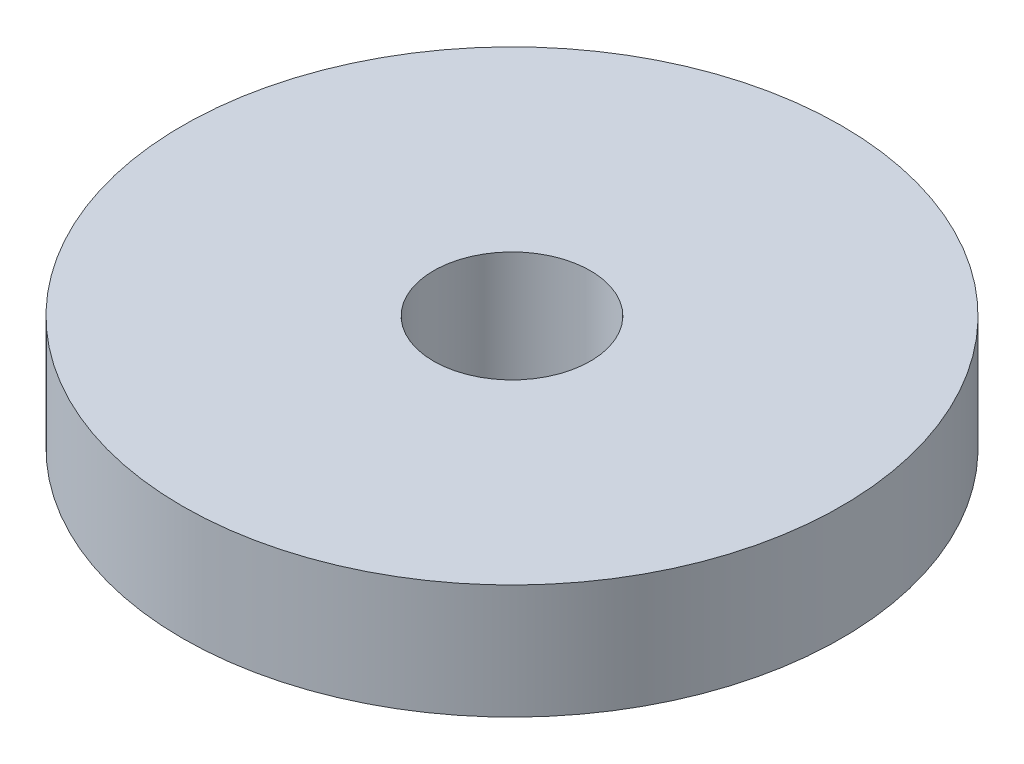
from build123d import *

# Parameters (mm, degrees)
SKETCH1_R           = 13.716
SKETCH1_R_2         = 3.2639
BOSS_EXTRUDE1_DEPTH = 4.7625


with BuildPart() as part:
    # Sketch1 → Boss-Extrude1 (new body)
    with BuildSketch(Plane(origin=(0, 0, 0), x_dir=(1, 0, 0), z_dir=(0, 1, 0))):
        Circle(SKETCH1_R)
        Circle(SKETCH1_R_2, mode=Mode.SUBTRACT)
    extrude(amount=BOSS_EXTRUDE1_DEPTH)


solid = part.part
